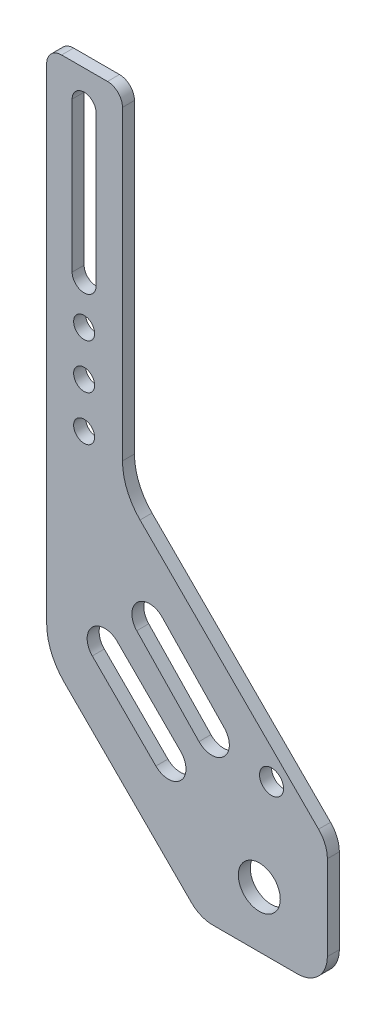
from build123d import *

# Parameters (mm, degrees)
SKETCH1_R           = 3.5
SKETCH1_R_2         = 7
SKETCH1_R_3         = 4
BOSS_EXTRUDE1_DEPTH = 4


with BuildPart() as part:
    # Sketch1 → Boss-Extrude1 (new body)
    with BuildSketch(Plane.XY):
        with BuildLine():
            Line((55.379885617, -96.237749993), (83.664156864, -96.237749993))
            ThreePointArc((83.664156864, -96.237749993), (90.735224676, -93.308817805), (93.664156864, -86.237749993))
            Line((93.664156864, -86.237749993), (93.664156864, -57.953478746))
            ThreePointArc((93.664156864, -57.953478746), (92.902952189, -54.126644422), (90.735224676, -50.882410934))
            Line((90.735224676, -50.882410934), (31.159701747, 8.693111995))
            ThreePointArc((31.159701747, 8.693111995), (26.824246721, 15.181578972), (25.301837371, 22.835247619))
            Line((25.301837371, 22.835247619), (25.301837371, 125))
            ThreePointArc((25.301837371, 125), (23.837371277, 128.535533906), (20.301837371, 130))
            Line((20.301837371, 130), (5, 130))
            ThreePointArc((5, 130), (1.464466094, 128.535533906), (0, 125))
            Line((0, 125), (0, 5))
            Line((0, 5), (0, -36.715728753))
            ThreePointArc((0, -36.715728753), (1.52240935, -44.3693974), (5.857864376, -50.857864376))
            Line((5.857864376, -50.857864376), (48.308817805, -93.308817805))
            ThreePointArc((48.308817805, -93.308817805), (51.553051293, -95.476545318), (55.379885617, -96.237749993))
        make_face()
        with Locations((12.5, 55)):
            Circle(SKETCH1_R, mode=Mode.SUBTRACT)
        with Locations((12.5, 40)):
            Circle(SKETCH1_R, mode=Mode.SUBTRACT)
        with Locations((12.5, 25)):
            Circle(SKETCH1_R, mode=Mode.SUBTRACT)
        with Locations((70.953796111, -77.513095535)):
            Circle(SKETCH1_R_2, mode=Mode.SUBTRACT)
        with Locations((75.03834495, -45)):
            Circle(SKETCH1_R_3, mode=Mode.SUBTRACT)
        with BuildLine():
            Line((38.555717556, -15.716967459), (59.317673007, -37.372017813))
            ThreePointArc((59.317673007, -37.372017813), (59.142526441, -45.690498717), (50.824045538, -45.515352151))
            Line((50.824045538, -45.515352151), (30.062090086, -23.860301797))
            ThreePointArc((30.062090086, -23.860301797), (30.237236652, -15.541820893), (38.555717556, -15.716967459))
        make_face(mode=Mode.SUBTRACT)
        with BuildLine():
            ThreePointArc((8.5, 69), (12.5, 65), (16.5, 69))
            Line((16.5, 69), (16.5, 119))
            ThreePointArc((16.5, 119), (12.5, 123), (8.5, 119))
            Line((8.5, 119), (8.5, 69))
        make_face(mode=Mode.SUBTRACT)
        with BuildLine():
            ThreePointArc((36.446439435, -59.766764), (44.766764, -59.766764), (44.766764, -51.446439435))
            Line((44.766764, -51.446439435), (23.553560565, -30.233236))
            ThreePointArc((23.553560565, -30.233236), (15.233236, -30.233236), (15.233236, -38.553560565))
            Line((15.233236, -38.553560565), (36.446439435, -59.766764))
        make_face(mode=Mode.SUBTRACT)
    extrude(amount=BOSS_EXTRUDE1_DEPTH)


solid = part.part
